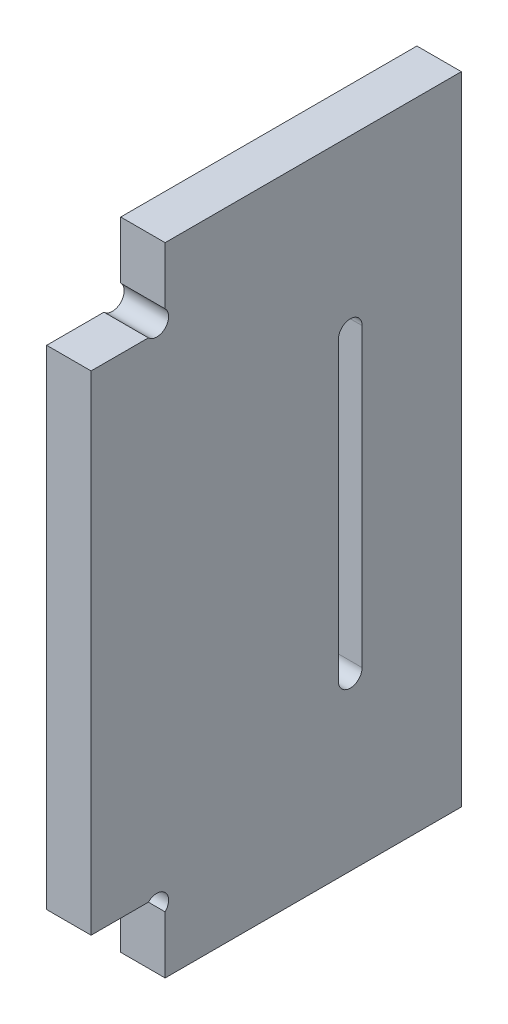
from build123d import *

# Parameters (mm, degrees)
EXTRUSION1_DEPTH        = 6
ENL_V_MAT_EXTRU_1_DEPTH = 2.2


with BuildPart() as part:
    # Esquisse1 → Extrusion1 (new body)
    with BuildSketch(Plane(origin=(0, 0, 0), x_dir=(0, 0, -1), z_dir=(1, 0, 0))):
        with BuildLine():
            Line((120, 249), (80, 249))
            Line((80, 249), (80, 241.2627417))
            ThreePointArc((80, 241.2627417), (80, 239), (77.7372583, 239))
            Line((77.7372583, 239), (70, 239))
            Line((70, 239), (70, 173))
            Line((70, 173), (77.7372583, 173))
            ThreePointArc((77.7372583, 173), (80, 173), (80, 170.7372583))
            Line((80, 170.7372583), (80, 163))
            Line((80, 163), (120, 163))
            Line((120, 163), (120, 249))
        make_face()
        with BuildLine():
            Line((106.6, 226), (106.6, 186))
            ThreePointArc((106.6, 186), (105, 184.4), (103.4, 186))
            Line((103.4, 186), (103.4, 226))
            ThreePointArc((103.4, 226), (105, 227.6), (106.6, 226))
        make_face(mode=Mode.SUBTRACT)
    extrude(amount=EXTRUSION1_DEPTH)

    # Esquisse2 → Enlèv. mat.-Extru.1 (cut)
    with BuildSketch(Plane.ZY):
        with BuildLine():
            Line((-117.55, 245), (-117.55, 167))
            ThreePointArc((-117.55, 167), (-116, 165.45), (-114.45, 167))
            Line((-114.45, 167), (-114.45, 245))
            ThreePointArc((-114.45, 245), (-116, 246.55), (-117.55, 245))
        make_face()
        with BuildLine():
            Line((-95.55, 167), (-95.55, 245))
            ThreePointArc((-95.55, 245), (-94, 246.55), (-92.45, 245))
            Line((-92.45, 245), (-92.45, 167))
            ThreePointArc((-92.45, 167), (-94, 165.45), (-95.55, 167))
        make_face()
    extrude(amount=-ENL_V_MAT_EXTRU_1_DEPTH, mode=Mode.SUBTRACT)


solid = part.part
